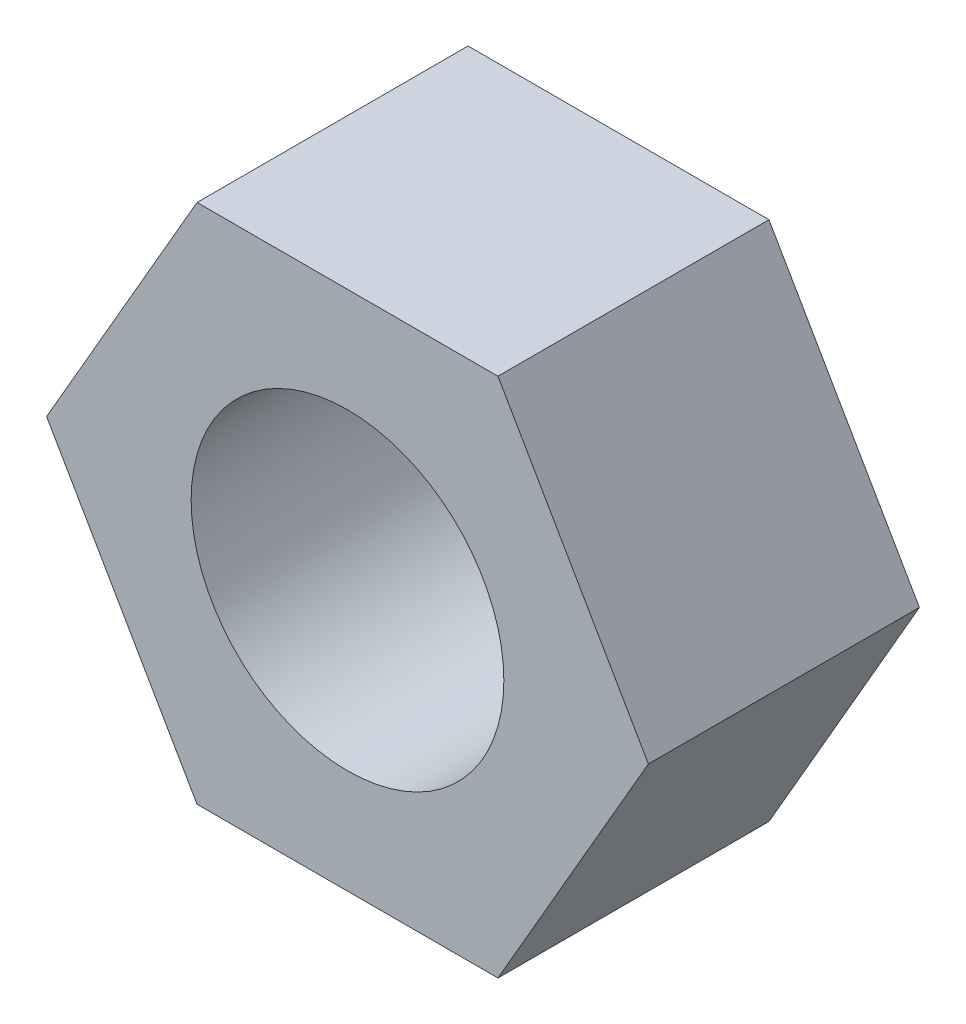
from build123d import *

# Parameters (mm, degrees)
BOSS_EXTRUDE1_DEPTH = 2.6
SKETCH2_R           = 3
CUT_EXTRUDE1_DEPTH  = 6.2


with BuildPart() as part:
    # Sketch1 → Boss-Extrude1 (new body, symmetric)
    with BuildSketch(Plane.XY):
        Polygon((5.773502692, 0), (2.886751346, 5), (-2.886751346, 5), (-5.773502692, 0), (-2.886751346, -5), (2.886751346, -5), align=None)
    extrude(amount=BOSS_EXTRUDE1_DEPTH, both=True)

    # Sketch2 → Cut-Extrude1 (cut, through all)
    with BuildSketch(Plane.XY.offset(2.6)):
        Circle(SKETCH2_R)
    extrude(amount=-CUT_EXTRUDE1_DEPTH, mode=Mode.SUBTRACT)


solid = part.part
